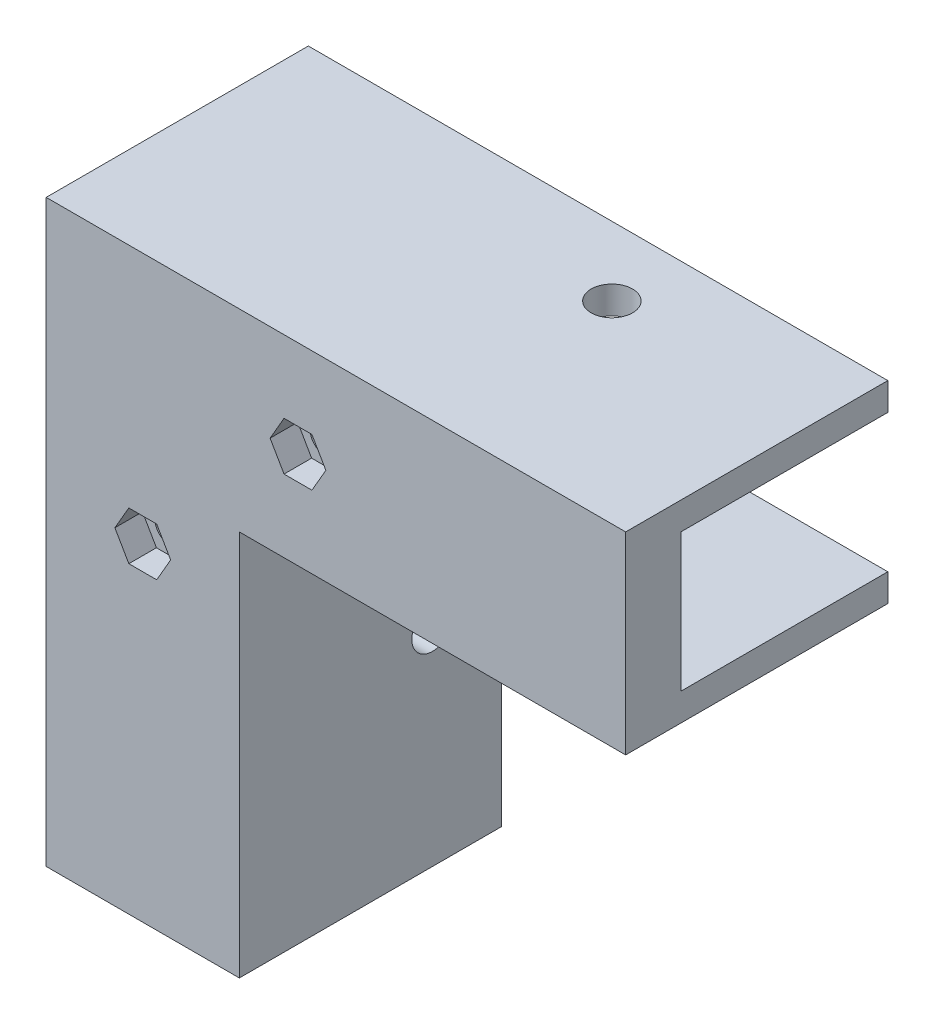
from build123d import *

# Parameters (mm, degrees)
BOSS_EXTRU_1_DEPTH      = 8
ENL_V_MAT_EXTRU_1_DEPTH = 4
ESQUISSE3_R             = 2.25
ENL_V_MAT_EXTRU_2_DEPTH = 5
BOSS_EXTRU_2_DEPTH      = 38
ESQUISSE5_R             = 3
ENL_V_MAT_EXTRU_3_DEPTH = 29
ESQUISSE6_R             = 3
ENL_V_MAT_EXTRU_4_DEPTH = 29


with BuildPart() as part:
    # Esquisse1 → Boss.-Extru.1 (new body)
    with BuildSketch(Plane.XY):
        Polygon((0, 0), (0, 60), (60, 60), (60, 80), (-20, 80), (-20, 0), align=None)
    extrude(amount=BOSS_EXTRU_1_DEPTH)

    # Esquisse2 → Enlèv. mat.-Extru.1 (cut)
    with BuildSketch(Plane.XY.offset(8)):
        Polygon((-14.041451884, 47.5), (-12.020725942, 51), (-7.979274058, 51), (-5.958548116, 47.5), (-7.979274058, 44), (-12.020725942, 44), align=None)
        Polygon((8.458548116, 70), (10.479274058, 73.5), (14.520725942, 73.5), (16.541451884, 70), (14.520725942, 66.5), (10.479274058, 66.5), align=None)
    extrude(amount=-ENL_V_MAT_EXTRU_1_DEPTH, mode=Mode.SUBTRACT)

    # Esquisse3 → Enlèv. mat.-Extru.2 (cut, through all)
    with BuildSketch(Plane.XY.offset(4)):
        with Locations((-10, 47.5)):
            Circle(ESQUISSE3_R)
        with Locations((12.5, 70)):
            Circle(ESQUISSE3_R)
    extrude(amount=-ENL_V_MAT_EXTRU_2_DEPTH, mode=Mode.SUBTRACT)

    # Esquisse4 → Boss.-Extru.2 (add)
    with BuildSketch(Plane.XY.offset(8)):
        Polygon((0, 0), (0, 60), (60, 60), (60, 56), (4, 56), (4, 0), align=None)
        Polygon((60, 80), (60, 84), (-24, 84), (-24, 0), (-20, 0), (-20, 80), align=None)
    extrude(amount=-BOSS_EXTRU_2_DEPTH)

    # Esquisse5 → Enlèv. mat.-Extru.3 (cut, through all)
    with BuildSketch(Plane.XZ.offset(-56)):
        with Locations((30, -20)):
            Circle(ESQUISSE5_R)
    extrude(amount=-ENL_V_MAT_EXTRU_3_DEPTH, mode=Mode.SUBTRACT)

    # Esquisse6 → Enlèv. mat.-Extru.4 (cut, through all)
    with BuildSketch(Plane(origin=(4, 0, 0), x_dir=(0, 0, -1), z_dir=(1, 0, 0))):
        with Locations(Location((20, 30, 0), (0, 0, 90))):  # turned: the seam where the file's is
            Circle(ESQUISSE6_R)
    extrude(amount=-ENL_V_MAT_EXTRU_4_DEPTH, mode=Mode.SUBTRACT)


solid = part.part
